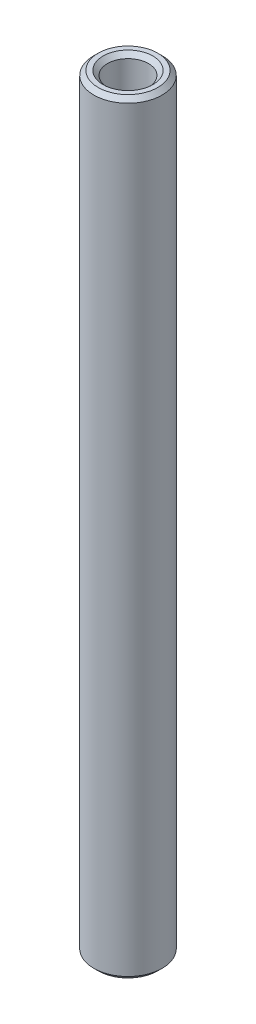
from build123d import *

# Parameters (mm, degrees)
SKETCH1_R           = 1.984375
SKETCH1_R_2         = 1.190625
BOSS_EXTRUDE1_DEPTH = 22.225
CHAMFER1_SIZE       = 0.254


with BuildPart() as part:
    # Sketch1 → Boss-Extrude1 (new body, symmetric)
    with BuildSketch(Plane(origin=(0, 0, 0), x_dir=(1, 0, 0), z_dir=(0, 1, 0))):
        Circle(SKETCH1_R)
        Circle(SKETCH1_R_2, mode=Mode.SUBTRACT)
    extrude(amount=BOSS_EXTRUDE1_DEPTH, both=True)

    # Chamfer1
    chamfer1_edges = [part.edges().sort_by_distance(p)[0] for p in [
        (-1.984375, -22.225, 0),
        (-1.984375, 22.225, 0),
        (-1.190625, -22.225, 0),
        (-1.190625, 22.225, 0),
    ]]
    chamfer(chamfer1_edges, length=CHAMFER1_SIZE)


solid = part.part
